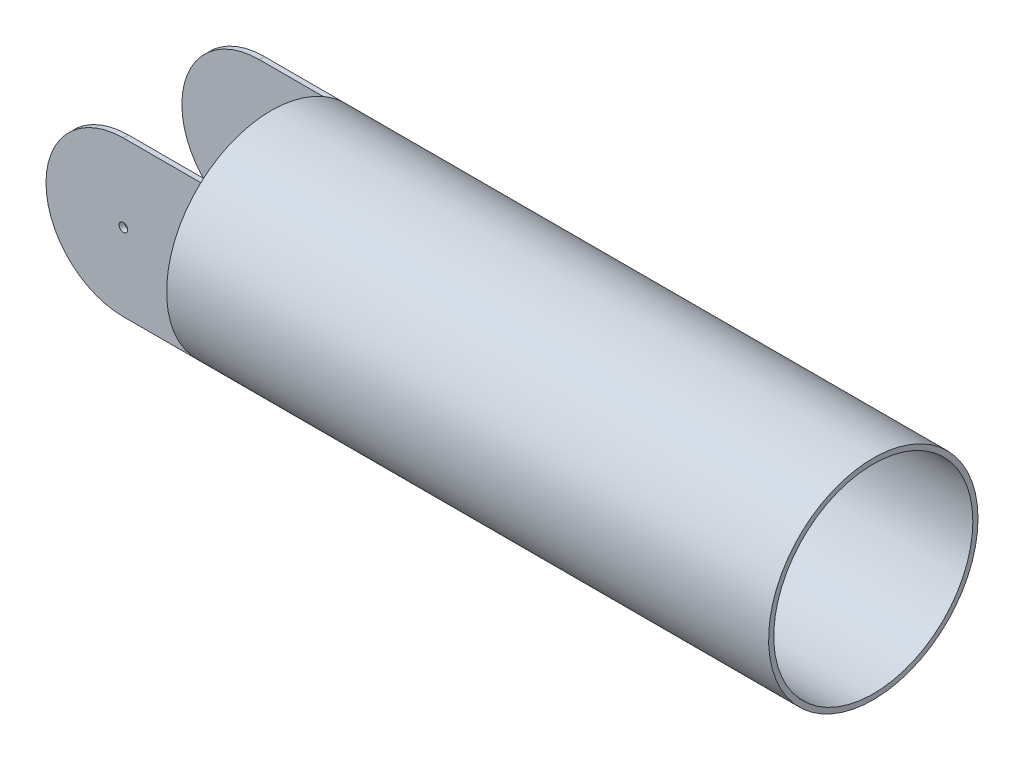
from build123d import *

# Parameters (mm, degrees)
IZIM1_W                     = 180
IZIM1_H                     = 180
Y_KSEKLIK_EKSTR_ZYON1_DEPTH = 164
IZIM3_R                     = 121.753850042
Y_KSEKLIK_EKSTR_ZYON2_DEPTH = 700
KES_EKSTR_ZYON1_DEPTH       = 700
IZIM5_W                     = 180
IZIM5_H                     = 152
KES_EKSTR_ZYON2_DEPTH       = 700
IZIM6_R                     = 5
KES_EKSTR_ZYON3_DEPTH       = 700
IZIM7_R                     = 115.753850042
KES_EKSTR_ZYON4_DEPTH       = 694


with BuildPart() as part:
    # Çizim1 → Yükseklik-Ekstrüzyon1 (new body)
    with BuildSketch(Plane.XY):
        with Locations((90, 90)):
            Rectangle(IZIM1_W, IZIM1_H)
    extrude(amount=Y_KSEKLIK_EKSTR_ZYON1_DEPTH)

    # Çizim3 → Yükseklik-Ekstrüzyon2 (add)
    with BuildSketch(Plane(origin=(180, 0, 0), x_dir=(0, 0, -1), z_dir=(1, 0, 0))):
        with Locations((-82, 90)):
            Circle(IZIM3_R)
    extrude(amount=Y_KSEKLIK_EKSTR_ZYON2_DEPTH)

    # Çizim4 → Kes-Ekstrüzyon1 (cut)
    with BuildSketch(Plane.XY.offset(164)):
        with BuildLine():
            ThreePointArc((0, 90), (26.360389693, 153.639610307), (90, 180))
            Line((90, 180), (0, 180))
            Line((0, 180), (0, 90))
        make_face()
        with BuildLine():
            ThreePointArc((90, 0), (26.360389693, 26.360389693), (0, 90))
            Line((0, 90), (0, 0))
            Line((0, 0), (90, 0))
        make_face()
    extrude(amount=-KES_EKSTR_ZYON1_DEPTH, mode=Mode.SUBTRACT)

    # Çizim5 → Kes-Ekstrüzyon2 (cut)
    with BuildSketch(Plane(origin=(0, 180, 0), x_dir=(1, 0, 0), z_dir=(0, 1, 0))):
        with Locations((90, -82)):
            Rectangle(IZIM5_W, IZIM5_H)
    extrude(amount=-KES_EKSTR_ZYON2_DEPTH, mode=Mode.SUBTRACT)

    # Çizim6 → Kes-Ekstrüzyon3 (cut)
    with BuildSketch(Plane.XY.offset(164)):
        with Locations((90, 90)):
            Circle(IZIM6_R)
    extrude(amount=-KES_EKSTR_ZYON3_DEPTH, mode=Mode.SUBTRACT)

    # Çizim7 → Kes-Ekstrüzyon4 (cut)
    with BuildSketch(Plane(origin=(880, 0, 0), x_dir=(0, 0, -1), z_dir=(1, 0, 0))):
        with Locations((-82, 90)):
            Circle(IZIM7_R)
    extrude(amount=-KES_EKSTR_ZYON4_DEPTH, mode=Mode.SUBTRACT)


solid = part.part
